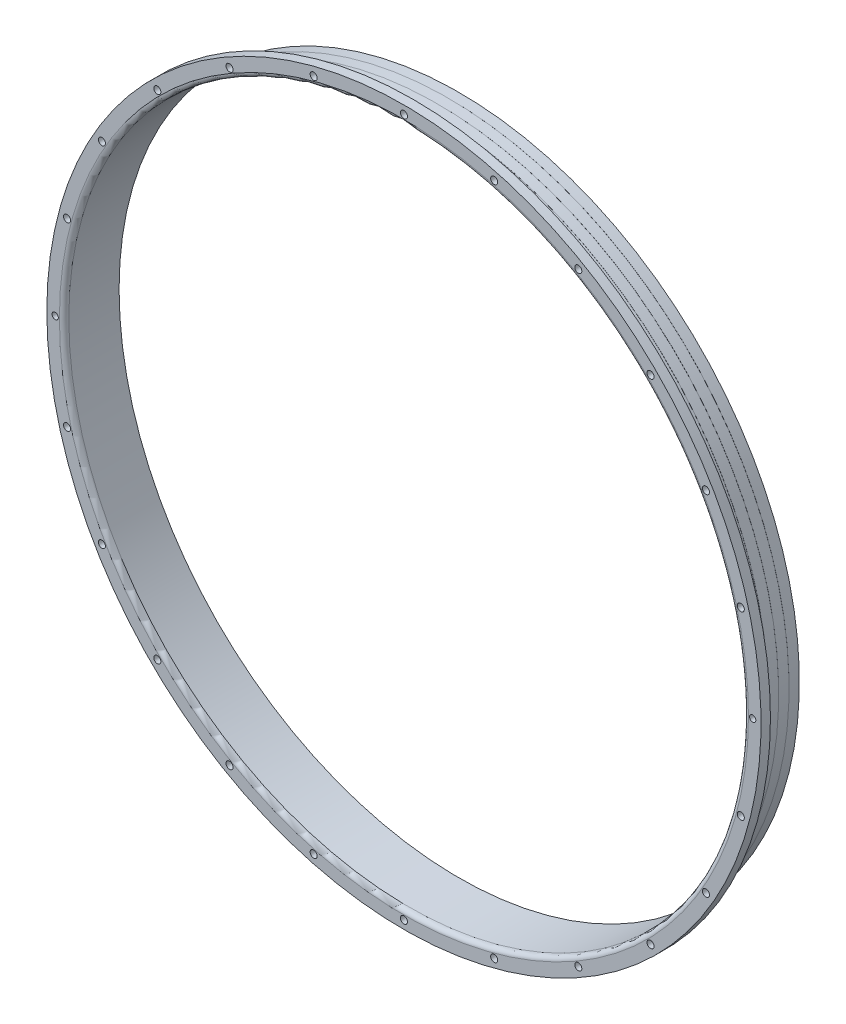
from build123d import *

# Parameters (mm, degrees)
FILLET1_R            = 2
M4_CLEARANCE_HOLE1_D = 4.5
CIRPATTERN1_COUNT    = 24
SKETCH6_R            = 2.25
SKETCH6_R_2          = 2
BOSS_EXTRUDE1_DEPTH  = 6


with BuildPart() as part:
    # Sweep1: sweep along a path in Sketch1
    with BuildLine(Plane.XY) as sweep1_path:
        CenterArc((0, 0), 216.325, 0, 360)
    # Sketch2 → Sweep1 (sweep)
    with BuildSketch(Plane(origin=(0, 0, 0), x_dir=(0, 0, -1), z_dir=(1, 0, 0))):
        with BuildLine():
            Line((0, 227.325), (0, 219.325))
            ThreePointArc((0, 219.325), (0.878679656, 217.203679656), (3, 216.325))
            Line((3, 216.325), (35, 216.325))
            Line((35, 216.325), (35, 217.39))
            Line((35, 217.39), (3.1, 217.39))
            ThreePointArc((3.1, 217.39), (1.685786438, 217.975786438), (1.1, 219.39))
            Line((1.1, 219.39), (1.1, 227.325))
            Line((1.1, 227.325), (0, 227.325))
        make_face()
    sweep(path=sweep1_path.line)

    # Sketch7 → Revolve3 (revolve)
    with BuildSketch(Plane(origin=(0, 0, 0), x_dir=(0, 0, -1), z_dir=(1, 0, 0)), mode=Mode.PRIVATE) as revolve3_sk:
        with BuildLine():
            Line((6, 216.325), (3, 216.325))
            ThreePointArc((3, 216.325), (0.878679656, 217.203679656), (0, 219.325))
            Line((0, 219.325), (0, 227.325))
            Line((0, 227.325), (6, 227.325))
            Line((6, 227.325), (6, 216.325))
        make_face()
    revolve(revolve3_sk.sketch.rotate(Axis((0, 0, 0), (0, 0, -1)), 270), axis=Axis((0, 0, 0), (0, 0, -1)))  # turned: the seam where the file's is

    # Fillet1
    fillet1_edges = [part.edges().sort_by_distance(p)[0] for p in [
        (-217.39, 0, -6),
    ]]
    fillet(fillet1_edges, radius=FILLET1_R)

    # Sketch8 → Cut-Revolve1 (revolve, cut)
    with BuildSketch(Plane(origin=(0, 0, 0), x_dir=(0, 0, -1), z_dir=(1, 0, 0)), mode=Mode.PRIVATE) as cut_revolve1_sk:
        Polygon((35, 216.751), (28.40975, 216.751), (28.19675, 216.964), (21.6065, 216.964), (21.3935, 217.177), (14.80325, 217.177), (14.59025, 217.39), (35, 217.39), align=None)
    revolve(cut_revolve1_sk.sketch.rotate(Axis((0, 0, -21), (0, 0, 1)), 90), axis=Axis((0, 0, -21), (0, 0, 1)), mode=Mode.SUBTRACT)  # turned: the seam where the file's is

    # M4 Clearance Hole1 (through all)
    with Locations(Plane.XY):
        with Locations((0, 222)):
            m4_clearance_hole1 = Hole(M4_CLEARANCE_HOLE1_D / 2)

    # CirPattern1: M4 Clearance Hole1 ×24 about axis
    cirpattern1_axis = Axis((0, 0, 0), (0, 0, 1))
    for i in range(1, CIRPATTERN1_COUNT):
        add(m4_clearance_hole1.rotate(cirpattern1_axis, i * 360 / CIRPATTERN1_COUNT), mode=Mode.SUBTRACT)

    # Sketch6 → Boss-Extrude1 (add)
    with BuildSketch(Plane.XY):
        with Locations((-222, 0)):
            Circle(SKETCH6_R)
        with Locations((-222, 0)):
            Circle(SKETCH6_R_2, mode=Mode.SUBTRACT)
        with Locations((222, 0)):
            Circle(SKETCH6_R)
        with Locations((222, 0)):
            Circle(SKETCH6_R_2, mode=Mode.SUBTRACT)
    extrude(amount=-BOSS_EXTRUDE1_DEPTH)


solid = part.part
